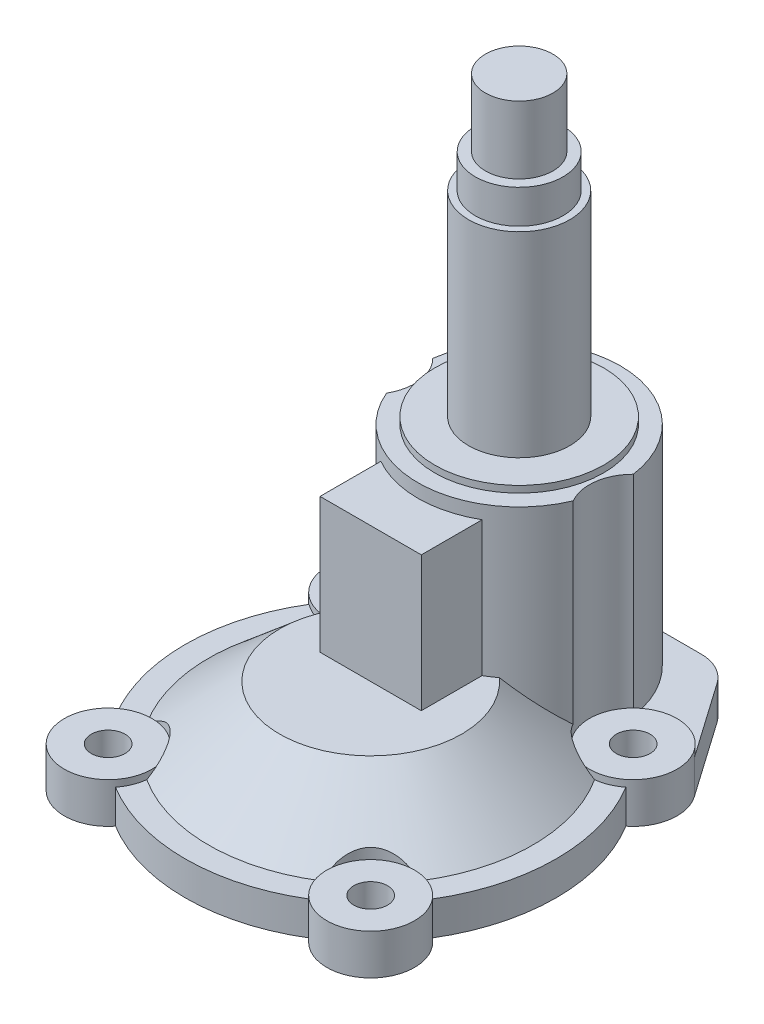
from build123d import *

# Parameters (mm, degrees)
SKETCH1_R               = 27.5
BOSS_EXTRUDE1_DEPTH     = 5
SKETCH3_R               = 2.5
CUT_EXTRUDE1_DEPTH      = 6
CUT_EXTRUDE1_DEPTH_BACK = 1
SKETCH3_3_R             = 6.5
SKETCH3_3_R_2           = 2.5
BOSS_EXTRUDE2_DEPTH     = 6
SKETCH5_R               = 6.5
CUT_EXTRUDE2_DEPTH      = 6
BOSS_EXTRUDE3_DEPTH     = 31
SKETCH7_R               = 12.5
BOSS_EXTRUDE4_DEPTH     = 1
SKETCH8_R               = 7.5
BOSS_EXTRUDE5_DEPTH     = 29
SKETCH9_R               = 6.5
BOSS_EXTRUDE6_DEPTH     = 5
SKETCH10_R              = 5
BOSS_EXTRUDE7_DEPTH     = 10
BOSS_EXTRUDE11_DEPTH    = 5
SKETCH13_W              = 15
SKETCH13_H              = 11.899909518
BOSS_EXTRUDE12_DEPTH    = 20


with BuildPart() as part:
    # Sketch1 → Boss-Extrude1 (new body)
    with BuildSketch(Plane(origin=(0, 0, 0), x_dir=(1, 0, 0), z_dir=(0, 1, 0))):
        Circle(SKETCH1_R)
    extrude(amount=BOSS_EXTRUDE1_DEPTH)

    # Sketch3 → Cut-Extrude1 (cut, two sides)
    with BuildSketch(Plane(origin=(0, 0, 0), x_dir=(1, 0, 0), z_dir=(0, 1, 0))) as cut_extrude1_sk:
        with Locations((-19.445436483, -19.445436483)):
            Circle(SKETCH3_R)
        with Locations((-19.445436483, 19.445436483)):
            Circle(SKETCH3_R)
        with Locations((19.445436483, 19.445436483)):
            Circle(SKETCH3_R)
        with Locations((19.445436483, -19.445436483)):
            Circle(SKETCH3_R)
    extrude(amount=CUT_EXTRUDE1_DEPTH, mode=Mode.SUBTRACT)
    extrude(cut_extrude1_sk.sketch, amount=-CUT_EXTRUDE1_DEPTH_BACK, mode=Mode.SUBTRACT)

    # Sketch3_3 → Boss-Extrude2 (add)
    with BuildSketch(Plane(origin=(0, 0, 0), x_dir=(1, 0, 0), z_dir=(0, 1, 0))):
        with Locations((-19.445436483, -19.445436483)):
            Circle(SKETCH3_3_R)
        with Locations((-19.445436483, -19.445436483)):
            Circle(SKETCH3_3_R_2, mode=Mode.SUBTRACT)
        with Locations((-19.445436483, 19.445436483)):
            Circle(SKETCH3_3_R)
        with Locations((-19.445436483, 19.445436483)):
            Circle(SKETCH3_3_R_2, mode=Mode.SUBTRACT)
        with Locations((19.445436483, 19.445436483)):
            Circle(SKETCH3_3_R)
        with Locations((19.445436483, 19.445436483)):
            Circle(SKETCH3_3_R_2, mode=Mode.SUBTRACT)
        with Locations((19.445436483, -19.445436483)):
            Circle(SKETCH3_3_R)
        with Locations((19.445436483, -19.445436483)):
            Circle(SKETCH3_3_R_2, mode=Mode.SUBTRACT)
    extrude(amount=BOSS_EXTRUDE2_DEPTH)

    # Sketch4 → Revolve1 (revolve)
    with BuildSketch(Plane.XY):
        Polygon((0, 5), (-24, 5), (-13.5, 14), (0, 14), align=None)
    revolve(axis=Axis((0, 14, 0), (0, -1, 0)))

    # Sketch5 → Cut-Extrude2 (cut)
    with BuildSketch(Plane(origin=(0, 6, 0), x_dir=(1, 0, 0), z_dir=(0, 1, 0))):
        with Locations((19.445436483, -19.445436483)):
            Circle(SKETCH5_R)
        with Locations((19.445436483, 19.445436483)):
            Circle(SKETCH5_R)
        with Locations((-19.445436483, 19.445436483)):
            Circle(SKETCH5_R)
        with Locations((-19.445436483, -19.445436483)):
            Circle(SKETCH5_R)
    extrude(amount=CUT_EXTRUDE2_DEPTH, mode=Mode.SUBTRACT)

    # Sketch6 → Boss-Extrude3 (add)
    with BuildSketch(Plane(origin=(0, 5, 0), x_dir=(1, 0, 0), z_dir=(0, 1, 0))):
        with BuildLine():
            ThreePointArc((14.859059475, 24.051426706), (0, 37), (-14.859059475, 24.051426706))
            ThreePointArc((-14.859059475, 24.051426706), (-13.323926947, 21.631099084), (-12.9789923, 18.78581566))
            ThreePointArc((-12.9789923, 18.78581566), (-13.26319033, 17.437992209), (-13.825025584, 16.180320661))
            ThreePointArc((-13.825025584, 16.180320661), (0, 7), (13.825025584, 16.180320661))
            ThreePointArc((13.825025584, 16.180320661), (13.26319033, 17.437992209), (12.9789923, 18.78581566))
            ThreePointArc((12.9789923, 18.78581566), (13.323926947, 21.631099084), (14.859059475, 24.051426706))
        make_face()
    extrude(amount=BOSS_EXTRUDE3_DEPTH)

    # Sketch7 → Boss-Extrude4 (add)
    with BuildSketch(Plane(origin=(0, 36, 0), x_dir=(1, 0, 0), z_dir=(0, 1, 0))):
        with Locations((0, 22)):
            Circle(SKETCH7_R)
    extrude(amount=BOSS_EXTRUDE4_DEPTH)

    # Sketch8 → Boss-Extrude5 (add)
    with BuildSketch(Plane(origin=(0, 37, 0), x_dir=(1, 0, 0), z_dir=(0, 1, 0))):
        with Locations((0, 22)):
            Circle(SKETCH8_R)
    extrude(amount=BOSS_EXTRUDE5_DEPTH)

    # Sketch9 → Boss-Extrude6 (add)
    with BuildSketch(Plane(origin=(0, 66, 0), x_dir=(1, 0, 0), z_dir=(0, 1, 0))):
        with Locations((0, 22)):
            Circle(SKETCH9_R)
    extrude(amount=BOSS_EXTRUDE6_DEPTH)

    # Sketch10 → Boss-Extrude7 (add)
    with BuildSketch(Plane(origin=(0, 71, 0), x_dir=(1, 0, 0), z_dir=(0, 1, 0))):
        with Locations((0, 22)):
            Circle(SKETCH10_R)
    extrude(amount=BOSS_EXTRUDE7_DEPTH)

    # Sketch12 → Boss-Extrude11 (add)
    with BuildSketch(Plane(origin=(0, 0, 0), x_dir=(1, 0, 0), z_dir=(0, 1, 0))):
        with BuildLine():
            Line((24.769924771, 23.173683319), (16.880143567, 34.441458618))
            ThreePointArc((16.880143567, 34.441458618), (14.735722981, 36.322064999), (11.965231301, 37))
            Line((11.965231301, 37), (0, 37))
            ThreePointArc((0, 37), (-9.854658782, 33.30865599), (-14.859059475, 24.051426706))
            ThreePointArc((-14.859059475, 24.051426706), (-14.589838885, 23.766683059), (-14.338266086, 23.466233734))
            ThreePointArc((-14.338266086, 23.466233734), (0, 27.5), (14.338266086, 23.466233734))
            ThreePointArc((14.338266086, 23.466233734), (14.589838885, 23.766683059), (14.859059475, 24.051426706))
            ThreePointArc((14.859059475, 24.051426706), (20.018856424, 25.920093969), (24.769924771, 23.173683319))
        make_face()
    extrude(amount=BOSS_EXTRUDE11_DEPTH)

    # Sketch13 → Boss-Extrude12 (add)
    with BuildSketch(Plane(origin=(0, 14, 0), x_dir=(1, 0, 0), z_dir=(0, 1, 0))):
        with Locations((0, 5.949954759)):
            Rectangle(SKETCH13_W, SKETCH13_H)
    extrude(amount=BOSS_EXTRUDE12_DEPTH)


solid = part.part
